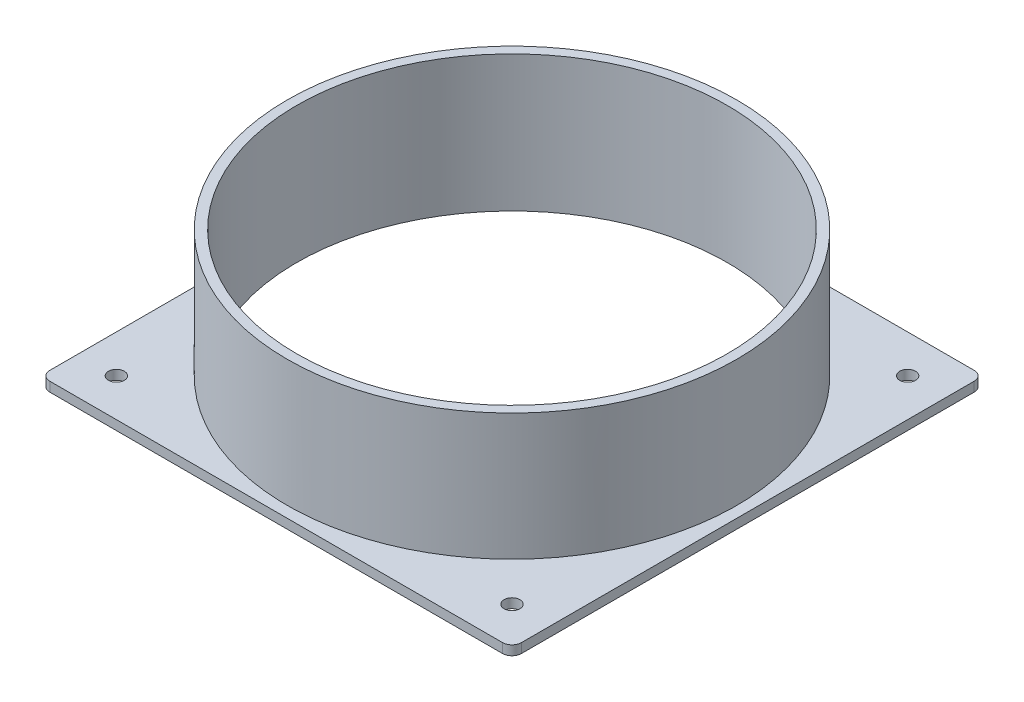
from build123d import *

# Parameters (mm, degrees)
SKETCH4_R           = 68
SKETCH4_R_2         = 2.5
BOSS_EXTRUDE5_DEPTH = 3
SKETCH5_R           = 71
SKETCH5_R_2         = 68
BOSS_EXTRUDE6_DEPTH = 40


with BuildPart() as part:
    # Sketch4 → Boss-Extrude5 (new body)
    with BuildSketch(Plane(origin=(0, 0, 0), x_dir=(1, 0, 0), z_dir=(0, 1, 0))):
        with BuildLine():
            Line((-71.5, 74.5), (71.5, 74.5))
            ThreePointArc((71.5, 74.5), (73.621320344, 73.621320344), (74.5, 71.5))
            Line((74.5, 71.5), (74.5, -71.5))
            ThreePointArc((74.5, -71.5), (73.621320344, -73.621320344), (71.5, -74.5))
            Line((71.5, -74.5), (-71.5, -74.5))
            ThreePointArc((-71.5, -74.5), (-73.621320344, -73.621320344), (-74.5, -71.5))
            Line((-74.5, -71.5), (-74.5, 71.5))
            ThreePointArc((-74.5, 71.5), (-73.621320344, 73.621320344), (-71.5, 74.5))
        make_face()
        Circle(SKETCH4_R, mode=Mode.SUBTRACT)
        with Locations((-62.5, 62.5)):
            Circle(SKETCH4_R_2, mode=Mode.SUBTRACT)
        with Locations((62.5, 62.5)):
            Circle(SKETCH4_R_2, mode=Mode.SUBTRACT)
        with Locations((62.5, -62.5)):
            Circle(SKETCH4_R_2, mode=Mode.SUBTRACT)
        with Locations((-62.5, -62.5)):
            Circle(SKETCH4_R_2, mode=Mode.SUBTRACT)
    extrude(amount=BOSS_EXTRUDE5_DEPTH)

    # Sketch5 → Boss-Extrude6 (add)
    with BuildSketch(Plane(origin=(0, 3, 0), x_dir=(1, 0, 0), z_dir=(0, 1, 0))):
        Circle(SKETCH5_R)
        Circle(SKETCH5_R_2, mode=Mode.SUBTRACT)
    extrude(amount=BOSS_EXTRUDE6_DEPTH)


solid = part.part
